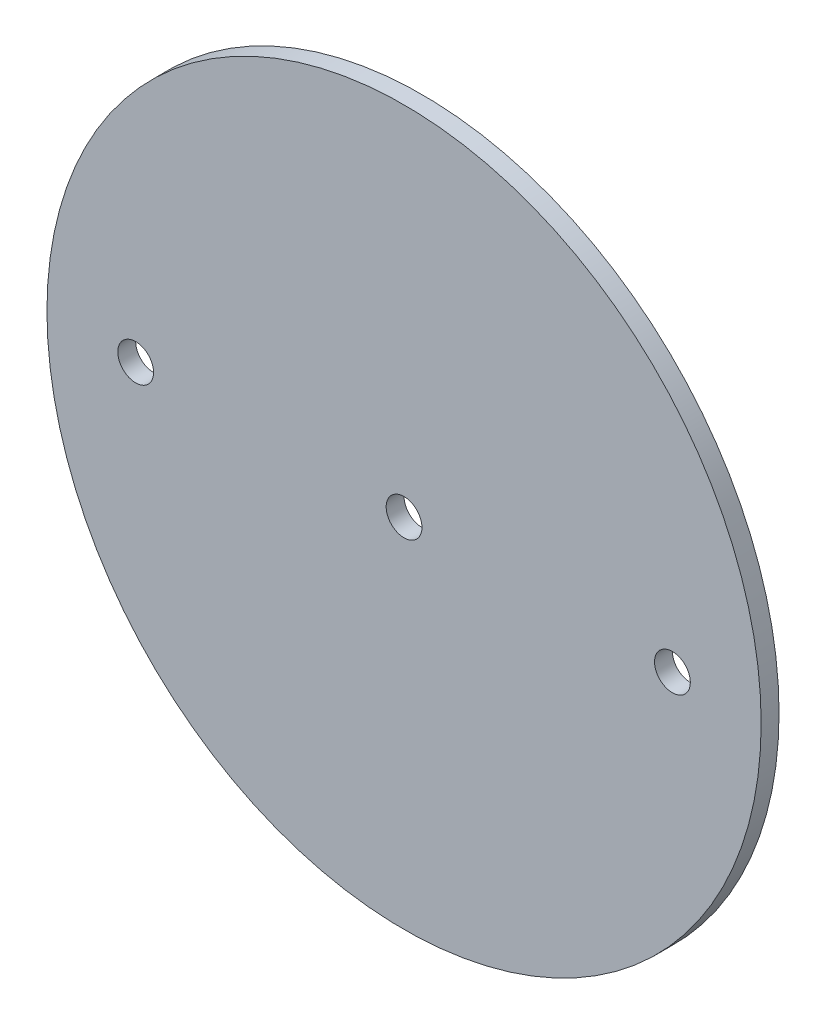
from build123d import *

# Parameters (mm, degrees)
SKETCH1_R                   = 63.373
BOSS_EXTRUDE1_DEPTH         = 1.5875
F_1_4_0_25_DIAMETER_HOLE1_D = 6.35


with BuildPart() as part:
    # Sketch1 → Boss-Extrude1 (new body, symmetric)
    with BuildSketch(Plane.XY):
        Circle(SKETCH1_R)
    extrude(amount=BOSS_EXTRUDE1_DEPTH, both=True)

    # 1/4 (0.25) Diameter Hole1 (through all)
    with Locations(Plane.XY.offset(1.5875)):
        with Locations((-47.625, 0), (0, 0), (47.625, 0)):
            Hole(F_1_4_0_25_DIAMETER_HOLE1_D / 2)


solid = part.part
